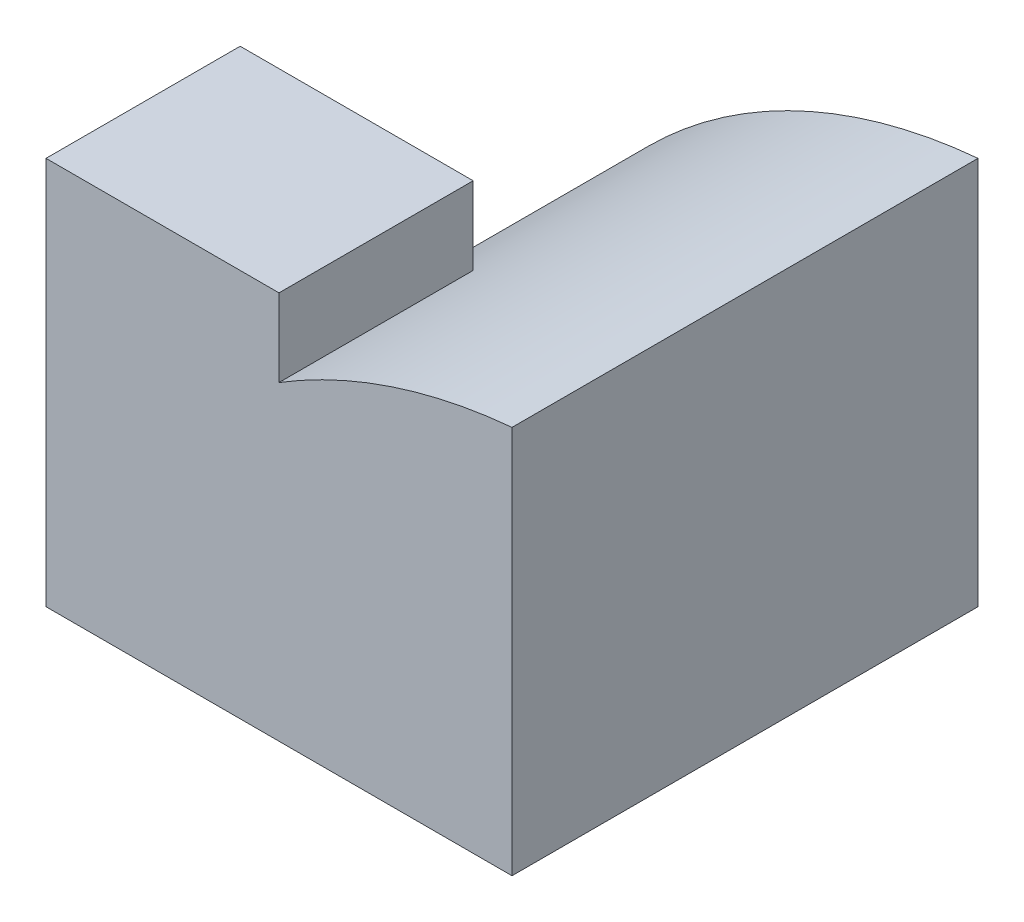
from build123d import *

# Parameters (mm, degrees)
SKETCH1_W           = 6
SKETCH1_H           = 6
BOSS_EXTRUDE1_DEPTH = 5
CUT_EXTRUDE12_DEPTH = 3.5
CUT_EXTRUDE13_DEPTH = 3.5


with BuildPart() as part:
    # Sketch1 → Boss-Extrude1 (new body)
    with BuildSketch(Plane(origin=(0, 0, 0), x_dir=(1, 0, 0), z_dir=(0, 1, 0))):
        Rectangle(SKETCH1_W, SKETCH1_H)
    extrude(amount=BOSS_EXTRUDE1_DEPTH)

    # Sketch13 → Cut-Extrude12 (cut)
    with BuildSketch(Plane(origin=(0, 0, -3), x_dir=(-1, 0, 0), z_dir=(0, 0, -1))):
        with BuildLine():
            ThreePointArc((-3, 5), (0.780941195, 3.437129434), (3, 0))
            Line((3, 0), (3, 5))
            Line((3, 5), (-3, 5))
        make_face()
    extrude(amount=-CUT_EXTRUDE12_DEPTH, mode=Mode.SUBTRACT)

    # Sketch14 → Cut-Extrude13 (cut)
    with BuildSketch(Plane(origin=(0, 0, 0.5), x_dir=(-1, 0, 0), z_dir=(0, 0, -1))):
        with BuildLine():
            ThreePointArc((-3, 5), (-1.441597312, 4.675208063), (0, 4))
            Line((0, 4), (0, 5))
            Line((0, 5), (-3, 5))
        make_face()
    extrude(amount=-CUT_EXTRUDE13_DEPTH, mode=Mode.SUBTRACT)


solid = part.part
